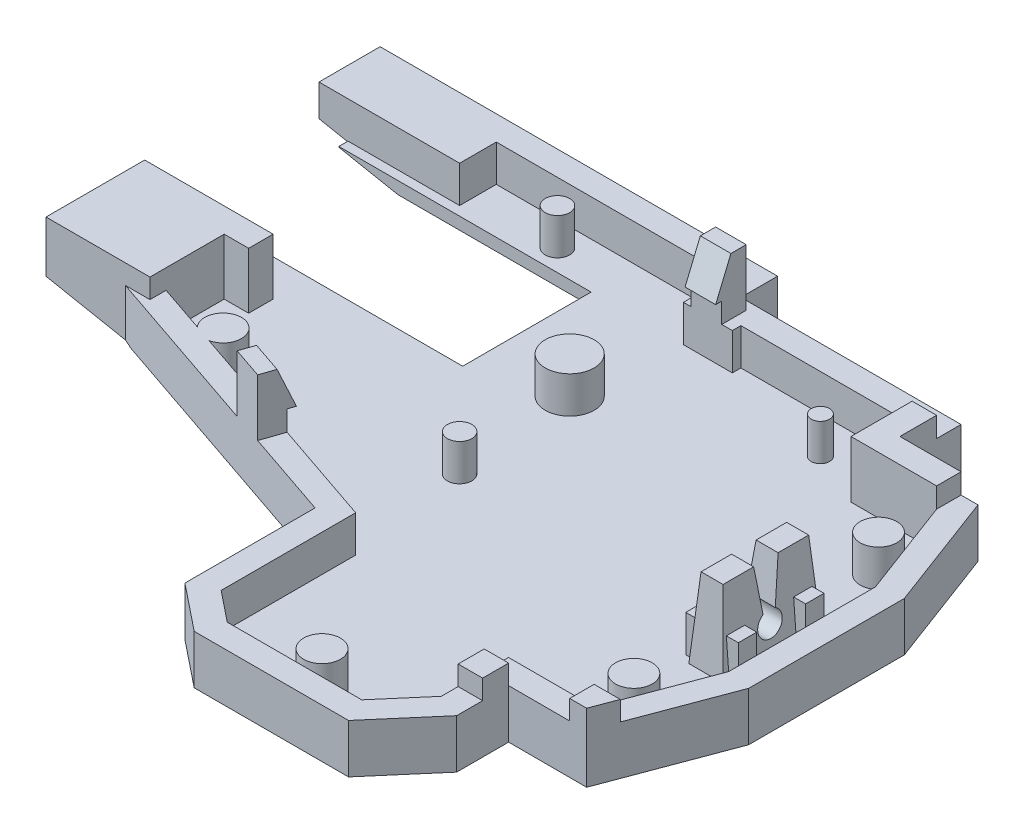
from build123d import *

# Parameters (mm, degrees)
SKETCH13_W           = 50
SKETCH13_H           = 45
BOSS_EXTRUDE4_DEPTH  = 1.6
SKETCH14_W           = 10
SKETCH14_H           = 8
CUT_EXTRUDE6_DEPTH   = 2.6
SKETCH15_W           = 18
SKETCH15_H           = 3
CUT_EXTRUDE7_DEPTH   = 2.6
SKETCH16_W           = 4
SKETCH16_H           = 0.7
CUT_EXTRUDE8_DEPTH   = 2.6
CUT_EXTRUDE9_DEPTH   = 2.6
SKETCH18_W           = 21.109590793
SKETCH18_H           = 22.840524871
CUT_EXTRUDE10_DEPTH  = 2.6
CUT_EXTRUDE11_DEPTH  = 2.6
SKETCH22_W           = 2
SKETCH22_H           = 3
CUT_EXTRUDE12_DEPTH  = 2.6
CUT_EXTRUDE13_DEPTH  = 2.6
CUT_EXTRUDE14_DEPTH  = 2.6
SKETCH25_W           = 2.8
SKETCH25_H           = 8
CUT_EXTRUDE15_DEPTH  = 2.6
BOSS_EXTRUDE6_DEPTH  = 6
SKETCH30_W           = 2.8
SKETCH30_H           = 8
BOSS_EXTRUDE7_DEPTH  = 3.5
CUT_EXTRUDE16_DEPTH  = 4.6
SKETCH32_W           = 2.8
SKETCH32_H           = 8
BOSS_EXTRUDE8_DEPTH  = 4.6
CUT_EXTRUDE18_DEPTH  = 4.6
SKETCH37_R           = 1
CUT_EXTRUDE19_DEPTH  = 4.6
CUT_EXTRUDE20_DEPTH  = 4.6
CUT_EXTRUDE21_START  = 6
CUT_EXTRUDE21_DEPTH  = 20.059798
BOSS_EXTRUDE9_DEPTH  = 4.6
SKETCH44_W           = 4.3
SKETCH44_H           = 1.5
BOSS_EXTRUDE11_DEPTH = 3
SKETCH45_R           = 1.5
SKETCH45_R_2         = 1
SKETCH45_R_3         = 1.999622229
SKETCH45_R_4         = 1.503341979
SKETCH45_R_5         = 0.75
BOSS_EXTRUDE12_DEPTH = 3
SKETCH46_W           = 2.5
SKETCH46_H           = 2
SKETCH46_W_2         = 2
BOSS_EXTRUDE13_DEPTH = 1.65
SKETCH47_W           = 3
SKETCH47_H           = 3
BOSS_EXTRUDE14_DEPTH = 3
SKETCH48_W           = 2
SKETCH48_H           = 16.336241737
CUT_EXTRUDE22_DEPTH  = 3
SKETCH49_W           = 21.336241737
SKETCH49_H           = 3
BOSS_EXTRUDE15_DEPTH = 13
SKETCH50_W           = 67
SKETCH50_H           = 49
BOSS_EXTRUDE16_DEPTH = 3
SKETCH51_W           = 5
SKETCH51_H           = 11
BOSS_EXTRUDE17_DEPTH = 15.6
CUT_EXTRUDE23_DEPTH  = 1.65
SKETCH53_W           = 2
SKETCH53_H           = 2.129349353
BOSS_EXTRUDE18_DEPTH = 1.6
SKETCH55_W           = 2.5
SKETCH55_H           = 2.5
BOSS_EXTRUDE20_DEPTH = 3
CUT_EXTRUDE24_DEPTH  = 3
SKETCH58_W           = 20
SKETCH58_H           = 10.5
SKETCH58_W_2         = 2
SKETCH58_H_2         = 2
CUT_EXTRUDE29_DEPTH  = 1
BOSS_EXTRUDE21_DEPTH = 3
BOSS_EXTRUDE22_REACH = 41.731
SKETCH61_W           = 2.5
SKETCH61_H           = 1.65
CUT_EXTRUDE30_DEPTH  = 3
CUT_EXTRUDE31_REACH  = 43.731
SKETCH64_W           = 2.551500858
SKETCH64_H           = 4.310788114
CUT_EXTRUDE32_DEPTH  = 4.65
SKETCH65_W           = 2
SKETCH65_H           = 2
BOSS_EXTRUDE23_DEPTH = 4
SKETCH66_W           = 2
SKETCH66_H           = 2
BOSS_EXTRUDE24_DEPTH = 1.6
SKETCH67_W           = 2.5
SKETCH67_H           = 2
BOSS_EXTRUDE25_DEPTH = 3
CUT_EXTRUDE33_DEPTH  = 3
BOSS_EXTRUDE26_DEPTH = 1.65
SKETCH70_W           = 5.055009343
SKETCH70_H           = 5.560438358
CUT_EXTRUDE34_DEPTH  = 3
BOSS_EXTRUDE27_DEPTH = 3
CUT_EXTRUDE35_DEPTH  = 3
BOSS_EXTRUDE28_REACH = 39.863
CUT_EXTRUDE36_DEPTH  = 3
FILLET8_R            = 1
SKETCH76_W           = 7
SKETCH76_H           = 14.5
BOSS_EXTRUDE29_DEPTH = 14.5
BOSS_EXTRUDE30_DEPTH = 2
CUT_EXTRUDE37_DEPTH  = 2
BOSS_EXTRUDE31_DEPTH = 2.684479
SKETCH85_W           = 30.566158209
SKETCH85_H           = 1.725230041
BOSS_EXTRUDE33_DEPTH = 3
BOSS_EXTRUDE34_DEPTH = 3
BOSS_EXTRUDE35_DEPTH = 3
SKETCH88_W           = 27.09375
SKETCH88_H           = 14.5
BOSS_EXTRUDE36_DEPTH = 1.6
SKETCH90_W           = 7
SKETCH90_H           = 14.5
BOSS_EXTRUDE37_DEPTH = 1.6
SKETCH93_W           = 5
SKETCH93_H           = 11
BOSS_EXTRUDE38_DEPTH = 0.5
SKETCH94_W           = 8.605758832
SKETCH94_H           = 2
BOSS_EXTRUDE39_DEPTH = 15.6
SKETCH96_W           = 8.605758832
SKETCH96_H           = 2
BOSS_EXTRUDE40_DEPTH = 0.5
SKETCH97_W           = 2
SKETCH97_H           = 49
BOSS_EXTRUDE41_DEPTH = 19.1
SKETCH98_W           = 69
SKETCH98_H           = 2
BOSS_EXTRUDE42_DEPTH = 19.1
SKETCH99_W           = 2
SKETCH99_H           = 3
BOSS_EXTRUDE43_DEPTH = 2.087376
SKETCH100_W          = 2
SKETCH100_H          = 51
BOSS_EXTRUDE45_DEPTH = 19.1
SKETCH101_W          = 71
SKETCH101_H          = 2
BOSS_EXTRUDE46_DEPTH = 19.1
BOSS_EXTRUDE47_DEPTH = 16.1
BOSS_EXTRUDE48_DEPTH = 16.1
FILLET9_R            = 2
SKETCH105_OUTSIDE_W  = 91.128
SKETCH105_OUTSIDE_H  = 73.128
CUT_EXTRUDE38_DEPTH  = 3
SKETCH106_W          = 77.0560479
SKETCH106_H          = 58.523580684
CUT_EXTRUDE39_DEPTH  = 20.1
SKETCH107_W          = 13.37564089
SKETCH107_H          = 6.179627402
CUT_EXTRUDE40_DEPTH  = 11.5
CUT_EXTRUDE41_DEPTH  = 4
SKETCH114_W          = 66.336817547
SKETCH114_H          = 51.668552302
CUT_EXTRUDE42_DEPTH  = 2
BOSS_EXTRUDE49_DEPTH = 6.5
SKETCH116_W          = 0.628599621
SKETCH116_H          = 10.5
CUT_EXTRUDE43_DEPTH  = 6.5
SKETCH117_W          = 8.5
SKETCH117_H          = 8.070282703
BOSS_EXTRUDE50_DEPTH = 1.6
SKETCH121_W          = 41.947556189
SKETCH121_H          = 104.538908281
CUT_EXTRUDE44_DEPTH  = 2.374278057


with BuildPart() as part:
    # Sketch13 → Boss-Extrude4 (new body)
    with BuildSketch(Plane(origin=(0, 0, 0), x_dir=(1, 0, 0), z_dir=(0, 1, 0))):
        with Locations((25, -22.5)):
            Rectangle(SKETCH13_W, SKETCH13_H)
    extrude(amount=BOSS_EXTRUDE4_DEPTH)

    # Sketch14 → Cut-Extrude6 (cut, through all)
    with BuildSketch(Plane(origin=(0, 1.6, 0), x_dir=(1, 0, 0), z_dir=(0, 1, 0))):
        with Locations((45, -4)):
            Rectangle(SKETCH14_W, SKETCH14_H)
    extrude(amount=-CUT_EXTRUDE6_DEPTH, mode=Mode.SUBTRACT)

    # Sketch15 → Cut-Extrude7 (cut, through all)
    with BuildSketch(Plane(origin=(0, 1.6, 0), x_dir=(1, 0, 0), z_dir=(0, 1, 0))):
        with Locations((31, -1.5)):
            Rectangle(SKETCH15_W, SKETCH15_H)
    extrude(amount=-CUT_EXTRUDE7_DEPTH, mode=Mode.SUBTRACT)

    # Sketch16 → Cut-Extrude8 (cut, through all)
    with BuildSketch(Plane(origin=(0, 1.6, 0), x_dir=(1, 0, 0), z_dir=(0, 1, 0))):
        with Locations((24, -3.35)):
            Rectangle(SKETCH16_W, SKETCH16_H)
    extrude(amount=-CUT_EXTRUDE8_DEPTH, mode=Mode.SUBTRACT)

    # Sketch17 → Cut-Extrude9 (cut, through all)
    with BuildSketch(Plane(origin=(0, 1.6, 0), x_dir=(1, 0, 0), z_dir=(0, 1, 0))):
        Polygon((47, -8), (50, -16), (65.881056194, -16), (65.881056194, 17.957346821), (47, 17.957346821), align=None)
    extrude(amount=-CUT_EXTRUDE9_DEPTH, mode=Mode.SUBTRACT)

    # Sketch18 → Cut-Extrude10 (cut, through all)
    with BuildSketch(Plane(origin=(0, 1.6, 0), x_dir=(1, 0, 0), z_dir=(0, 1, 0))):
        with Locations((50.554795396, -47.420262436)):
            Rectangle(SKETCH18_W, SKETCH18_H)
    extrude(amount=-CUT_EXTRUDE10_DEPTH, mode=Mode.SUBTRACT)

    # Sketch21 → Cut-Extrude11 (cut, through all)
    with BuildSketch(Plane(origin=(0, 1.6, 0), x_dir=(1, 0, 0), z_dir=(0, 1, 0))):
        Polygon((50, -28), (47, -36), (47, -49.297594069), (75.196774358, -49.297594069), (75.196774358, -28), align=None)
    extrude(amount=-CUT_EXTRUDE11_DEPTH, mode=Mode.SUBTRACT)

    # Sketch22 → Cut-Extrude12 (cut, through all)
    with BuildSketch(Plane(origin=(0, 1.6, 0), x_dir=(1, 0, 0), z_dir=(0, 1, 0))):
        with Locations((1, -20.836241737)):
            Rectangle(SKETCH22_W, SKETCH22_H)
    extrude(amount=-CUT_EXTRUDE12_DEPTH, mode=Mode.SUBTRACT)

    # Sketch23 → Cut-Extrude13 (cut, through all)
    with BuildSketch(Plane(origin=(0, 1.6, 0), x_dir=(1, 0, 0), z_dir=(0, 1, 0))):
        Polygon((23.5, -45), (23.5, -32), (0, -26.336241737), (-30.2261683, -26.336241737), (-30.2261683, -63.188280898), (23.5, -63.188280898), align=None)
    extrude(amount=-CUT_EXTRUDE13_DEPTH, mode=Mode.SUBTRACT)

    # Sketch24 → Cut-Extrude14 (cut, through all)
    with BuildSketch(Plane(origin=(0, 1.6, 0), x_dir=(1, 0, 0), z_dir=(0, 1, 0))):
        Polygon((23.5, -43), (7.491129632, -43), (7.491129632, -69.550234766), (44.754002286, -69.550234766), (44.754002286, -41.5), (40, -41.5), (37, -45), (26, -45), align=None)
    extrude(amount=-CUT_EXTRUDE14_DEPTH, mode=Mode.SUBTRACT)

    # Sketch25 → Cut-Extrude15 (cut, through all)
    with BuildSketch(Plane(origin=(0, 1.6, 0), x_dir=(1, 0, 0), z_dir=(0, 1, 0))):
        with Locations((46.200745069, -22.059797812)):
            Rectangle(SKETCH25_W, SKETCH25_H)
    extrude(amount=-CUT_EXTRUDE15_DEPTH, mode=Mode.SUBTRACT)

    # Sketch28 → Boss-Extrude6 (add)
    with BuildSketch(Plane.XZ):
        Polygon((42, 38), (42, 42.239848152), (37.919869845, 47), (25.298437881, 47), (21.5, 43.961249695), (21.5, 33.575244456), (-2, 27.911486193), (-2, -2), (24, -2), (24, 1), (42, 1), (42, 6), (48.386000936, 6), (52, 15.637330836), (52, 28.362669164), (48.386000936, 38), align=None)
    extrude(amount=BOSS_EXTRUDE6_DEPTH)

    # Sketch30 → Boss-Extrude7 (add)
    with BuildSketch(Plane(origin=(0, 0, 0), x_dir=(1, 0, 0), z_dir=(0, 1, 0))):
        with Locations((46.200745069, -22.059797812)):
            Rectangle(SKETCH30_W, SKETCH30_H)
    extrude(amount=BOSS_EXTRUDE7_DEPTH)

    # Sketch31 → Cut-Extrude16 (cut)
    with BuildSketch(Plane(origin=(0, 1.6, 0), x_dir=(1, 0, 0), z_dir=(0, 1, 0))):
        Polygon((37, -45), (40, -41.5), (40, -36), (47, -36), (50, -28), (50, -16), (47, -8), (40, -8), (40, -3), (26, -3), (26, -3.7), (22, -3.7), (22, 0), (0, 0), (0, -19.336241737), (2, -19.336241737), (2, -22.336241737), (0, -22.336241737), (0, -26.336241737), (23.5, -32), (23.5, -43), (26, -45), align=None)
    extrude(amount=-CUT_EXTRUDE16_DEPTH, mode=Mode.SUBTRACT)

    # Sketch32 → Boss-Extrude8 (add)
    with BuildSketch(Plane.XZ.offset(-1.6)):
        with Locations((46.200745069, 22.059797812)):
            Rectangle(SKETCH32_W, SKETCH32_H)
    extrude(amount=BOSS_EXTRUDE8_DEPTH)

    # Sketch35 → Cut-Extrude18 (cut)
    with BuildSketch(Plane(origin=(47.600745069, 0, 0), x_dir=(0, 0, -1), z_dir=(1, 0, 0))):
        Polygon((-22.059797812, 0), (-21.559797812, 0), (-21.059797812, 3.5), (-21.297672794, 5.165124873), (-23.257672794, 4.885124873), (-23.059797812, 3.5), (-22.559797812, 0), align=None)
    extrude(amount=-CUT_EXTRUDE18_DEPTH, mode=Mode.SUBTRACT)

    # Sketch37 → Cut-Extrude19 (cut)
    with BuildSketch(Plane(origin=(47.600745069, 0, 0), x_dir=(0, 0, -1), z_dir=(1, 0, 0))):
        with Locations((-22.059797812, -0.866025404)):
            Circle(SKETCH37_R)
    extrude(amount=-CUT_EXTRUDE19_DEPTH, mode=Mode.SUBTRACT)

    # Sketch39 → Cut-Extrude20 (cut)
    with BuildSketch(Plane.ZY.offset(-44.800745069)):
        Polygon((25.559797812, 3.5), (26.059797812, -3), (27.906381513, -2.8579551), (27.406381513, 3.6420449), align=None)
        Polygon((18.559797812, 3.5), (18.059797812, -3), (15.957253652, -2.838265834), (16.455739093, 3.6420449), align=None)
    extrude(amount=-CUT_EXTRUDE20_DEPTH, mode=Mode.SUBTRACT)

    # Sketch41 → Cut-Extrude21 (cut)
    with BuildSketch(Plane.XY.offset(CUT_EXTRUDE21_START)):
        Polygon((45.300745069, 3.5), (44.800745069, -3), (43.414957387, -2.893400947), (43.940591177, 3.939838325), align=None)
        Polygon((47.100745069, 3.5), (47.600745069, -3), (49.658968536, -2.841675118), (49.137313656, 3.939838325), align=None)
    extrude(amount=CUT_EXTRUDE21_DEPTH, mode=Mode.SUBTRACT)

    # Sketch43 → Boss-Extrude9 (add)
    with BuildSketch(Plane(origin=(0, 0, 0), x_dir=(1, 0, 0), z_dir=(0, 1, 0))):
        Polygon((47, -8), (50, -16), (51.170411472, -13.425094762), (48.386000936, -6), (42.818763345, -6), (42.818763345, -8), align=None)
    extrude(amount=-BOSS_EXTRUDE9_DEPTH)

    # Sketch44 → Boss-Extrude11 (add)
    with BuildSketch(Plane(origin=(0, -3, 0), x_dir=(1, 0, 0), z_dir=(0, 1, 0))):
        with Locations((46.200745069, -19.309797812)):
            Rectangle(SKETCH44_W, SKETCH44_H)
        with Locations((46.200745069, -24.809797812)):
            Rectangle(SKETCH44_W, SKETCH44_H)
    extrude(amount=BOSS_EXTRUDE11_DEPTH)

    # Sketch45 → Boss-Extrude12 (add)
    with BuildSketch(Plane(origin=(0, -3, 0), x_dir=(1, 0, 0), z_dir=(0, 1, 0))):
        with Locations((46.25, -12)):
            Circle(SKETCH45_R)
        with Locations((46.25, -32)):
            Circle(SKETCH45_R)
        with Locations((22, -22)):
            Circle(SKETCH45_R_2)
        with Locations((21, -12)):
            Circle(SKETCH45_R_3)
        with Locations((31.75, -43)):
            Circle(SKETCH45_R_4)
        with Locations((35.5, -6)):
            Circle(SKETCH45_R_5)
        with Locations((10, -2)):
            Circle(SKETCH45_R_2)
        with Locations((5, -24.336241737)):
            Circle(SKETCH45_R)
    extrude(amount=BOSS_EXTRUDE12_DEPTH)

    # Sketch46 → Boss-Extrude13 (add)
    with BuildSketch(Plane(origin=(0, 0, 0), x_dir=(1, 0, 0), z_dir=(0, 1, 0))):
        Polygon((14.137316506, -29.743490383), (16.567726059, -30.329245795), (16.099121729, -32.273573438), (13.668712176, -31.687818026), align=None)
        with Locations((23.883625006, -2.7)):
            Rectangle(SKETCH46_W, SKETCH46_H)
        with Locations((1, -20.932723283)):
            Rectangle(SKETCH46_W_2, SKETCH46_H)
        Polygon((47, -36), (48.872658355, -36.702246883), (49.750466959, -34.361423939), (47.877808604, -33.659177056), align=None)
        Polygon((40, -3), (40, -8), (47, -8), (47, -6), (42, -6), (42, -3), align=None)
    extrude(amount=BOSS_EXTRUDE13_DEPTH)

    # Sketch47 → Boss-Extrude14 (add)
    with BuildSketch(Plane(origin=(0, 0, 0), x_dir=(1, 0, 0), z_dir=(0, 1, 0))):
        with Locations((1.5, -1.5)):
            Rectangle(SKETCH47_W, SKETCH47_H)
    extrude(amount=-BOSS_EXTRUDE14_DEPTH)

    # Sketch48 → Cut-Extrude22 (cut)
    with BuildSketch(Plane(origin=(0, 0, 0), x_dir=(1, 0, 0), z_dir=(0, 1, 0))):
        with Locations((-1, -11.168120869)):
            Rectangle(SKETCH48_W, SKETCH48_H)
    extrude(amount=-CUT_EXTRUDE22_DEPTH, mode=Mode.SUBTRACT)

    # Sketch49 → Boss-Extrude15 (add)
    with BuildSketch(Plane.ZY.offset(2)):
        with Locations((8.668120869, -4.5)):
            Rectangle(SKETCH49_W, SKETCH49_H)
    extrude(amount=BOSS_EXTRUDE15_DEPTH)

    # Sketch50 → Boss-Extrude16 (add)
    with BuildSketch(Plane.XZ.offset(6)):
        with Locations((18.5, 22.5)):
            Rectangle(SKETCH50_W, SKETCH50_H)
    extrude(amount=-BOSS_EXTRUDE16_DEPTH)

    # Sketch51 → Boss-Extrude17 (add)
    with BuildSketch(Plane(origin=(0, -3, 0), x_dir=(1, 0, 0), z_dir=(0, 1, 0))):
        with Locations((49.5, -41.5)):
            Rectangle(SKETCH51_W, SKETCH51_H)
    extrude(amount=BOSS_EXTRUDE17_DEPTH)

    # Sketch52 → Cut-Extrude23 (cut)
    with BuildSketch(Plane(origin=(0, 1.65, 0), x_dir=(1, 0, 0), z_dir=(0, 1, 0))):
        Polygon((47.877808604, -33.659177056), (47, -36), (49.136000936, -36), (49.750466959, -34.361423939), align=None)
    extrude(amount=-CUT_EXTRUDE23_DEPTH, mode=Mode.SUBTRACT)

    # Sketch53 → Boss-Extrude18 (add)
    with BuildSketch(Plane(origin=(0, 0, 0), x_dir=(1, 0, 0), z_dir=(0, 1, 0))):
        with Locations((41, -39.055249399)):
            Rectangle(SKETCH53_W, SKETCH53_H)
    extrude(amount=BOSS_EXTRUDE18_DEPTH)

    # Sketch55 → Boss-Extrude20 (add)
    with BuildSketch(Plane(origin=(0, 1.65, 0), x_dir=(1, 0, 0), z_dir=(0, 1, 0))):
        with Locations((23.883625006, -2.95)):
            Rectangle(SKETCH55_W, SKETCH55_H)
    extrude(amount=BOSS_EXTRUDE20_DEPTH)

    # Sketch56 → Cut-Extrude24 (cut)
    with BuildSketch(Plane(origin=(25.133625006, 0, 0), x_dir=(0, 0, -1), z_dir=(1, 0, 0))):
        Polygon((-4.2, 1.65), (-2.95, 4.65), (-2.95, 7.68728323), (-6.59715338, 7.68728323), (-6.59715338, 1.641289328), align=None)
    extrude(amount=-CUT_EXTRUDE24_DEPTH, mode=Mode.SUBTRACT)

    # Sketch58 → Cut-Extrude29 (cut)
    with BuildSketch(Plane(origin=(0, -3, 0), x_dir=(1, 0, 0), z_dir=(0, 1, 0))):
        with Locations((4.5, -9)):
            Rectangle(SKETCH58_W, SKETCH58_H)
        with Locations((1, -18.248866233)):
            Rectangle(SKETCH58_W_2, SKETCH58_H_2)
    extrude(amount=-CUT_EXTRUDE29_DEPTH, mode=Mode.SUBTRACT)

    # Sketch60 → Boss-Extrude21 (add)
    with BuildSketch(Plane(origin=(0, -3, 0), x_dir=(1, 0, 0), z_dir=(0, 1, 0))):
        Polygon((0, -24), (23.5, -32), (0, -26.336241737), align=None)
    extrude(amount=BOSS_EXTRUDE21_DEPTH)

    # Boss-Extrude22: up to this face of the body (flat: up to its plane)
    boss_extrude22_end = Plane(part.part.faces().sort_by_distance((14.401539714, -1.5, 28.902651818))[0])
    # Sketch61 → Boss-Extrude22 (add, up to the picked face)
    with BuildSketch(Plane(origin=(-5.998871461, 0, 24.890447788), x_dir=(-0.972163821, 0, -0.234302165), z_dir=(0.234302165, 0, -0.972163821)), mode=Mode.PRIVATE) as boss_extrude22_sk1:
        with Locations((-21.962751827, 0.825)):
            Rectangle(SKETCH61_W, SKETCH61_H)
    boss_extrude22_tool1 = split(extrude(boss_extrude22_sk1.sketch, amount=BOSS_EXTRUDE22_REACH, mode=Mode.PRIVATE), bisect_by=boss_extrude22_end, keep=Keep.BOTH, mode=Mode.PRIVATE)
    add(boss_extrude22_tool1.solids().sort_by_distance((15.352521, 0.825, 30.036368))[0])

    # Sketch62 → Cut-Extrude30 (cut)
    with BuildSketch(Plane(origin=(0, 0, 0), x_dir=(1, 0, 0), z_dir=(0, 1, 0))):
        Polygon((0, -26), (-0.545193502, -28.262110548), (-9.931116312, -26), (-9.25988925, -22.847697277), align=None)
    extrude(amount=-CUT_EXTRUDE30_DEPTH, mode=Mode.SUBTRACT)

    # Cut-Extrude31: up to this face of the body (flat: up to its plane)
    cut_extrude31_end = Plane(part.part.faces().sort_by_distance((-1, -1.5, 25.659574468))[0])
    # Sketch63 → Cut-Extrude31 (cut, up to the picked face)
    with BuildSketch(Plane(origin=(-6.46747579, 0, 26.834775431), x_dir=(0.972163821, 0, 0.234302165), z_dir=(-0.234302165, 0, 0.972163821)), mode=Mode.PRIVATE) as cut_extrude31_sk1:
        Polygon((20.712751827, 0), (6.091856288, 0), (6.091856288, -3), (28.768274623, -3), (28.768274623, 0), (23.212751827, 0), (23.212751827, 1.65), (20.712751827, 1.65), align=None)
    cut_extrude31_tool1 = split(extrude(cut_extrude31_sk1.sketch, amount=-CUT_EXTRUDE31_REACH, mode=Mode.PRIVATE), bisect_by=cut_extrude31_end, keep=Keep.BOTH, mode=Mode.PRIVATE)
    add(cut_extrude31_tool1.solids().sort_by_distance((10.72932, -1.367082, 30.979392))[0], mode=Mode.SUBTRACT)

    # Sketch64 → Cut-Extrude32 (cut)
    with BuildSketch(Plane(origin=(0, 1.65, 0), x_dir=(1, 0, 0), z_dir=(0, 1, 0))):
        with Locations((1.275750429, -20.806985271)):
            Rectangle(SKETCH64_W, SKETCH64_H)
    extrude(amount=-CUT_EXTRUDE32_DEPTH, mode=Mode.SUBTRACT)

    # Sketch65 → Boss-Extrude23 (add)
    with BuildSketch(Plane(origin=(0, -4, 0), x_dir=(1, 0, 0), z_dir=(0, 1, 0))):
        with Locations((1, -18.248866233)):
            Rectangle(SKETCH65_W, SKETCH65_H)
    extrude(amount=BOSS_EXTRUDE23_DEPTH)

    # Sketch66 → Boss-Extrude24 (add)
    with BuildSketch(Plane(origin=(0, 0, 0), x_dir=(1, 0, 0), z_dir=(0, 1, 0))):
        with Locations((1, -18.248866233)):
            Rectangle(SKETCH66_W, SKETCH66_H)
    extrude(amount=BOSS_EXTRUDE24_DEPTH)

    # Sketch67 → Boss-Extrude25 (add)
    with BuildSketch(Plane(origin=(0, 1.6, 0), x_dir=(1, 0, 0), z_dir=(0, 1, 0))):
        with Locations((1.25, -18.248866233)):
            Rectangle(SKETCH67_W, SKETCH67_H)
    extrude(amount=BOSS_EXTRUDE25_DEPTH)

    # Sketch68 → Cut-Extrude33 (cut)
    with BuildSketch(Plane(origin=(0, 0, 17.248866233), x_dir=(-1, 0, 0), z_dir=(0, 0, -1))):
        Polygon((-2.5, 1.6), (-1.25, 4.6), (-1.25, 6.77486743), (-4.497451498, 6.77486743), (-4.497451498, 1.567063174), align=None)
    extrude(amount=-CUT_EXTRUDE33_DEPTH, mode=Mode.SUBTRACT)

    # Sketch69 → Boss-Extrude26 (add)
    with BuildSketch(Plane(origin=(0, 1.65, 0), x_dir=(1, 0, 0), z_dir=(0, 1, 0))):
        Polygon((14.344636536, -28.883280523), (16.885898362, -29.748390932), (16.275756374, -31.540683021), (13.734494548, -30.675572612), align=None)
    extrude(amount=-BOSS_EXTRUDE26_DEPTH)

    # Sketch70 → Cut-Extrude34 (cut)
    with BuildSketch(Plane.XY.offset(19.248866233)):
        with Locations((-0.027504672, 4.380219179)):
            Rectangle(SKETCH70_W, SKETCH70_H)
    extrude(amount=-CUT_EXTRUDE34_DEPTH, mode=Mode.SUBTRACT)

    # Sketch71 → Boss-Extrude27 (add)
    with BuildSketch(Plane(origin=(0, 1.65, 0), x_dir=(1, 0, 0), z_dir=(0, 1, 0))):
        Polygon((16.275756374, -31.540683021), (17.081415869, -29.174058256), (14.559846057, -28.298525857), (13.734494548, -30.675572612), align=None)
    extrude(amount=BOSS_EXTRUDE27_DEPTH)

    # Sketch72 → Cut-Extrude35 (cut)
    with BuildSketch(Plane(origin=(24.207602216, 0, 8.240885861), x_dir=(0.322263798, 0, -0.946649906), z_dir=(0.946649906, 0, 0.322263798))):
        Polygon((-22.112897557, 1.65), (-23.362897557, 4.65), (-23.362897557, 7.694800469), (-20.734818485, 7.694800469), (-20.734818485, 1.65), align=None)
    extrude(amount=-CUT_EXTRUDE35_DEPTH, mode=Mode.SUBTRACT)

    # Boss-Extrude28: up to this face of the body (flat: up to its plane)
    boss_extrude28_end = Plane(part.part.faces().sort_by_distance((14.039565542, 0.825, 29.779426567))[0])
    # Sketch73 → Boss-Extrude28 (add, up to the picked face)
    with BuildSketch(Plane(origin=(21.761963317, 0, 7.556127878), x_dir=(-0.328007452, 0, 0.944675136), z_dir=(-0.944675136, 0, -0.328007452)), mode=Mode.PRIVATE) as boss_extrude28_sk1:
        Polygon((24.473434161, 4.65), (23.223411105, 4.65), (21.973388049, 1.65), (22.580099427, 1.65), (24.473434161, 1.65), align=None)
    boss_extrude28_tool1 = split(extrude(boss_extrude28_sk1.sketch, amount=BOSS_EXTRUDE28_REACH, mode=Mode.PRIVATE), bisect_by=boss_extrude28_end, keep=Keep.BOTH, mode=Mode.PRIVATE)
    add(boss_extrude28_tool1.solids().sort_by_distance((14.053397, 2.983333, 29.757122))[0])

    # Sketch74 → Cut-Extrude36 (cut)
    with BuildSketch(Plane(origin=(0, -4, 0), x_dir=(1, 0, 0), z_dir=(0, 1, 0))):
        with BuildLine():
            Line((6.419171569, -6.169171569), (2.580828431, -6.169171569))
            ThreePointArc((2.580828431, -6.169171569), (-0.25, -9), (2.580828431, -11.830828431))
            Line((2.580828431, -11.830828431), (6.419171569, -11.830828431))
            ThreePointArc((6.419171569, -11.830828431), (9.25, -9), (6.419171569, -6.169171569))
        make_face()
    extrude(amount=-CUT_EXTRUDE36_DEPTH, mode=Mode.SUBTRACT)

    # Fillet8
    fillet8_edges = [part.edges().sort_by_distance(p)[0] for p in [
        (-0.25, -6, 9),
        (4.5, -6, 6.169171569),
        (9.25, -6, 9),
        (4.5, -6, 11.830828431),
    ]]
    fillet(fillet8_edges, radius=FILLET8_R)

    # Sketch76 → Boss-Extrude29 (add)
    with BuildSketch(Plane(origin=(0, -3, 0), x_dir=(1, 0, 0), z_dir=(0, 1, 0))):
        with Locations((-11.5, -39.75)):
            Rectangle(SKETCH76_W, SKETCH76_H)
    extrude(amount=BOSS_EXTRUDE29_DEPTH)

    # Sketch79 → Boss-Extrude30 (add)
    with BuildSketch(Plane(origin=(21.66634039, 0, 7.375775452), x_dir=(-0.322263798, 0, 0.946649906), z_dir=(-0.946649906, 0, -0.322263798))):
        Polygon((22.719597745, 0), (24.612897557, 0), (24.612897557, 4.65), (23.362851444, 4.65), (22.112805332, 1.65), (22.719597745, 1.65), align=None)
    extrude(amount=BOSS_EXTRUDE30_DEPTH)

    # Sketch80 → Cut-Extrude37 (cut)
    with BuildSketch(Plane(origin=(24.207602216, 0, 8.240885861), x_dir=(0.322263798, 0, -0.946649906), z_dir=(0.946649906, 0, 0.322263798))):
        Polygon((-22.112897557, 1.65), (-23.362897557, 4.65), (-24.612897557, 4.65), (-24.612897557, 0), (-22.719597745, 0), (-22.719597745, 1.65), align=None)
    extrude(amount=-CUT_EXTRUDE37_DEPTH, mode=Mode.SUBTRACT)

    # Sketch83 → Boss-Extrude31 (add)
    with BuildSketch(Plane(origin=(19.773040578, 0, 6.731247856), x_dir=(-0.322263798, 0, 0.946649906), z_dir=(-0.946649906, 0, -0.322263798))):
        Polygon((22.719597745, 1.65), (22.719597745, 0), (24.612897557, 0), (24.612897557, 4.65), (23.362851444, 4.65), (22.112805332, 1.65), align=None)
    extrude(amount=-BOSS_EXTRUDE31_DEPTH)

    # Sketch85 → Boss-Extrude33 (add)
    with BuildSketch(Plane(origin=(0, -3, 0), x_dir=(1, 0, 0), z_dir=(0, 1, 0))):
        with Locations((7.283079105, -33.362615021)):
            Rectangle(SKETCH85_W, SKETCH85_H)
    extrude(amount=BOSS_EXTRUDE33_DEPTH)

    # Sketch86 → Boss-Extrude34 (add)
    with BuildSketch(Plane(origin=(0, -3, 0), x_dir=(1, 0, 0), z_dir=(0, 1, 0))):
        Polygon((21.5, -43.961249695), (21.5, -34.225230041), (-8, -34.225230041), (-8, -47), (25.298437881, -47), align=None)
    extrude(amount=BOSS_EXTRUDE34_DEPTH)

    # Sketch87 → Boss-Extrude35 (add)
    with BuildSketch(Plane(origin=(0, -3, 0), x_dir=(1, 0, 0), z_dir=(0, 1, 0))):
        Polygon((37.919869845, -47), (47, -47), (47, -38), (42, -38), (42, -42.239848152), align=None)
    extrude(amount=BOSS_EXTRUDE35_DEPTH)

    # Sketch88 → Boss-Extrude36 (add)
    with BuildSketch(Plane(origin=(0, 0, 0), x_dir=(1, 0, 0), z_dir=(0, 1, 0))):
        with Locations((5.546875, -39.75)):
            Rectangle(SKETCH88_W, SKETCH88_H)
    extrude(amount=BOSS_EXTRUDE36_DEPTH)

    # Sketch90 → Boss-Extrude37 (add)
    with BuildSketch(Plane(origin=(0, 11.5, 0), x_dir=(1, 0, 0), z_dir=(0, 1, 0))):
        with Locations((-11.5, -39.75)):
            Rectangle(SKETCH90_W, SKETCH90_H)
    extrude(amount=BOSS_EXTRUDE37_DEPTH)

    # Sketch93 → Boss-Extrude38 (add)
    with BuildSketch(Plane(origin=(0, 12.6, 0), x_dir=(1, 0, 0), z_dir=(0, 1, 0))):
        with Locations((49.5, -41.5)):
            Rectangle(SKETCH93_W, SKETCH93_H)
    extrude(amount=BOSS_EXTRUDE38_DEPTH)

    # Sketch94 → Boss-Extrude39 (add)
    with BuildSketch(Plane(origin=(0, -3, 0), x_dir=(1, 0, 0), z_dir=(0, 1, 0))):
        with Locations((5.421445221, -31.5)):
            Rectangle(SKETCH94_W, SKETCH94_H)
    extrude(amount=BOSS_EXTRUDE39_DEPTH)

    # Sketch96 → Boss-Extrude40 (add)
    with BuildSketch(Plane(origin=(0, 12.6, 0), x_dir=(1, 0, 0), z_dir=(0, 1, 0))):
        with Locations((5.421445221, -31.5)):
            Rectangle(SKETCH96_W, SKETCH96_H)
    extrude(amount=BOSS_EXTRUDE40_DEPTH)

    # Sketch97 → Boss-Extrude41 (add)
    with BuildSketch(Plane.XZ.offset(6)):
        with Locations((-16, 22.5)):
            Rectangle(SKETCH97_W, SKETCH97_H)
    extrude(amount=-BOSS_EXTRUDE41_DEPTH)

    # Sketch98 → Boss-Extrude42 (add)
    with BuildSketch(Plane.XZ.offset(6)):
        with Locations((17.5, 48)):
            Rectangle(SKETCH98_W, SKETCH98_H)
    extrude(amount=-BOSS_EXTRUDE42_DEPTH)

    # Sketch99 → Boss-Extrude43 (add)
    with BuildSketch(Plane(origin=(0, 0, 19.336241737), x_dir=(-1, 0, 0), z_dir=(0, 0, -1))):
        with Locations((1, -1.5)):
            Rectangle(SKETCH99_W, SKETCH99_H)
    extrude(amount=BOSS_EXTRUDE43_DEPTH)

    # Sketch100 → Boss-Extrude45 (add)
    with BuildSketch(Plane.XZ.offset(6)):
        with Locations((53, 23.5)):
            Rectangle(SKETCH100_W, SKETCH100_H)
    extrude(amount=-BOSS_EXTRUDE45_DEPTH)

    # Sketch101 → Boss-Extrude46 (add)
    with BuildSketch(Plane.XZ.offset(6)):
        with Locations((18.5, -3)):
            Rectangle(SKETCH101_W, SKETCH101_H)
    extrude(amount=-BOSS_EXTRUDE46_DEPTH)

    # Sketch102 → Boss-Extrude47 (add)
    with BuildSketch(Plane(origin=(0, -3, 0), x_dir=(1, 0, 0), z_dir=(0, 1, 0))):
        with BuildLine():
            Line((50, 2), (50, 2.836676417))
            Line((50, 2.836676417), (52.928518438, 2.836676417))
            Line((52.928518438, 2.836676417), (52.928518438, 0))
            Line((52.928518438, 0), (52, 0))
            ThreePointArc((52, 0), (51.414213562, 1.414213562), (50, 2))
        make_face()
    extrude(amount=BOSS_EXTRUDE47_DEPTH)

    # Sketch103 → Boss-Extrude48 (add)
    with BuildSketch(Plane(origin=(0, -3, 0), x_dir=(1, 0, 0), z_dir=(0, 1, 0))):
        with BuildLine():
            Line((-13, 2), (-13, 3.319267165))
            Line((-13, 3.319267165), (-16.315139414, 3.319267165))
            Line((-16.315139414, 3.319267165), (-16.315139414, 0))
            Line((-16.315139414, 0), (-15, 0))
            ThreePointArc((-15, 0), (-14.414213562, 1.414213562), (-13, 2))
        make_face()
    extrude(amount=BOSS_EXTRUDE48_DEPTH)

    # Fillet9
    fillet9_edges = [part.edges().sort_by_distance(p)[0] for p in [
        (-17, -6, 22.5),
        (18.5, -6, 49),
        (-17, 3.55, 49),
        (54, -6, 22.5),
        (54, 3.55, 49),
        (18.5, -6, -4),
        (-17, 3.55, -4),
        (54, 3.55, -4),
    ]]
    fillet(fillet9_edges, radius=FILLET9_R)

    # Sketch105 outside → Cut-Extrude38 (cut)
    with BuildSketch(Plane(origin=(0, 13.1, 0), x_dir=(1, 0, 0), z_dir=(0, 1, 0))):
        with Locations((18.5, -22.5)):
            Rectangle(SKETCH105_OUTSIDE_W, SKETCH105_OUTSIDE_H)
        with BuildLine():
            Line((-16, 2), (-16, -47))
            ThreePointArc((-16, -47), (-15.707106781, -47.707106781), (-15, -48))
            Line((-15, -48), (52, -48))
            ThreePointArc((52, -48), (52.707106781, -47.707106781), (53, -47))
            Line((53, -47), (53, 2))
            ThreePointArc((53, 2), (52.707106781, 2.707106781), (52, 3))
            Line((52, 3), (-15, 3))
            ThreePointArc((-15, 3), (-15.707106781, 2.707106781), (-16, 2))
        make_face(mode=Mode.SUBTRACT)
    extrude(amount=-CUT_EXTRUDE38_DEPTH, mode=Mode.SUBTRACT)

    # Sketch106 → Cut-Extrude39 (cut, through all)
    with BuildSketch(Plane.XZ.offset(6)):
        with Locations((17.692589571, 21.631481201)):
            Rectangle(SKETCH106_W, SKETCH106_H)
        Polygon((-2, -2), (24, -2), (24, 1), (42, 1), (42, 6), (48.386000936, 6), (52, 15.637330836), (52, 28.362669164), (49.136000936, 36), (48.386000936, 38), (42, 37.990574723), (42, 42.239848152), (37.919869845, 47), (25.298437881, 47), (21.5, 43.961249695), (21.5, 33.319148936), (-2, 25.319148936), (-2, 17.248866233), (-8.372079234, 17.248866233), (-8.372079234, 3), (-2, 3), align=None, mode=Mode.SUBTRACT)
    extrude(amount=-CUT_EXTRUDE39_DEPTH, mode=Mode.SUBTRACT)

    # Sketch107 → Cut-Extrude40 (cut)
    with BuildSketch(Plane(origin=(0, 13.1, 0), x_dir=(1, 0, 0), z_dir=(0, 1, 0))):
        with Locations((44.784273424, -38.274312053)):
            Rectangle(SKETCH107_W, SKETCH107_H)
    extrude(amount=-CUT_EXTRUDE40_DEPTH, mode=Mode.SUBTRACT)

    # Sketch113 → Cut-Extrude41 (cut, through all)
    with BuildSketch(Plane(origin=(0, -3, 0), x_dir=(1, 0, 0), z_dir=(0, 1, 0))):
        Polygon((-6.128599621, -3), (-6.128599621, -14.861393841), (-2, -14.861393841), (-2, -17.248866233), (-9.246534053, -26.452427809), (-13.814435406, -0.657200841), (-2.974123127, 6.68981616), (-3.537653946, 5.974095989), align=None)
    extrude(amount=-CUT_EXTRUDE41_DEPTH, mode=Mode.SUBTRACT)

    # Sketch114 → Cut-Extrude42 (cut)
    with BuildSketch(Plane.XZ.offset(6)):
        with Locations((24.645555619, 22.809022442)):
            Rectangle(SKETCH114_W, SKETCH114_H)
    extrude(amount=-CUT_EXTRUDE42_DEPTH, mode=Mode.SUBTRACT)

    # Sketch115 → Boss-Extrude49 (add)
    with BuildSketch(Plane.ZY.offset(2)):
        Polygon((14.861393841, -3), (14.861393841, -4), (25.319148936, -4), (25.319148936, 0), (17.248866233, 0), (17.248866233, -3), align=None)
        Polygon((-2, 0), (-2, -4), (3, -4), (3, -3), (3, 0), align=None)
    extrude(amount=BOSS_EXTRUDE49_DEPTH)

    # Sketch116 → Cut-Extrude43 (cut)
    with BuildSketch(Plane(origin=(0, -3, 0), x_dir=(1, 0, 0), z_dir=(0, 1, 0))):
        with Locations((-5.81429981, -9)):
            Rectangle(SKETCH116_W, SKETCH116_H)
    extrude(amount=-CUT_EXTRUDE43_DEPTH, mode=Mode.SUBTRACT)

    # Sketch117 → Boss-Extrude50 (add)
    with BuildSketch(Plane(origin=(0, 0, 0), x_dir=(1, 0, 0), z_dir=(0, 1, 0))):
        with Locations((-4.25, -21.284007585)):
            Rectangle(SKETCH117_W, SKETCH117_H)
    extrude(amount=BOSS_EXTRUDE50_DEPTH)

    # Sketch121 → Cut-Extrude44 (cut, through all)
    with BuildSketch(Plane(origin=(-0.79645719, -4.097417033, 0), x_dir=(0.981627183, -0.190808995, 0), z_dir=(0.190808995, 0.981627183, 0))):
        with Locations((-1.037587354, -26.258689617)):
            Rectangle(SKETCH121_W, SKETCH121_H)
    extrude(amount=-CUT_EXTRUDE44_DEPTH, mode=Mode.SUBTRACT)


solid = part.part
